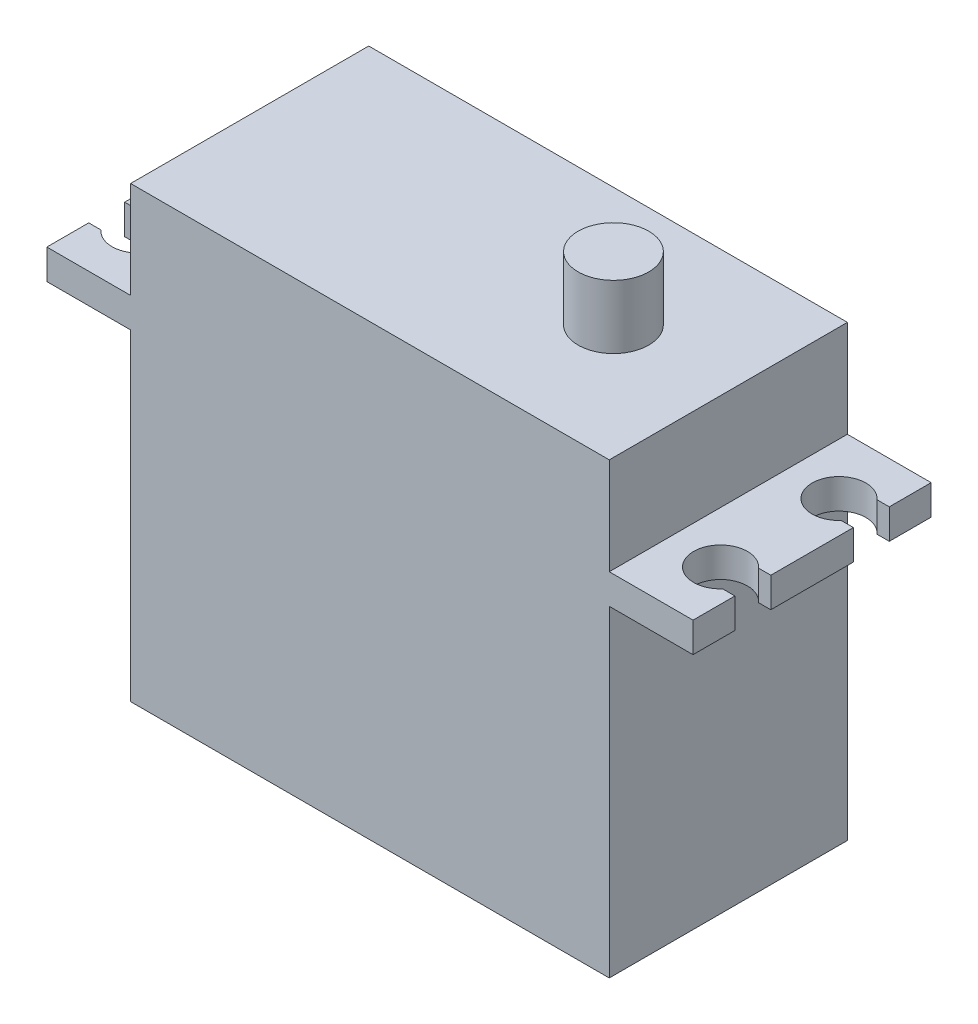
from build123d import *

# Parameters (mm, degrees)
SKETCH1_W           = 40
SKETCH1_H           = 19.9
BOSS_EXTRUDE1_DEPTH = 26.9
BOSS_EXTRUDE2_DEPTH = 2.5
SKETCH5_W           = 40
SKETCH5_H           = 19.9
BOSS_EXTRUDE3_DEPTH = 8.1


with BuildPart() as part:
    # Sketch1 → Boss-Extrude1 (new body)
    with BuildSketch(Plane(origin=(0, 0, 0), x_dir=(1, 0, 0), z_dir=(0, 1, 0))):
        Rectangle(SKETCH1_W, SKETCH1_H)
    extrude(amount=BOSS_EXTRUDE1_DEPTH)

    # Sketch4 → Boss-Extrude2 (add)
    with BuildSketch(Plane(origin=(0, 26.9, 0), x_dir=(1, 0, 0), z_dir=(0, 1, 0))):
        with BuildLine():
            Line((-27, -9.95), (27, -9.95))
            Line((27, -9.95), (27, -6.45))
            Line((27, -6.45), (25.977050983, -6.45))
            ThreePointArc((25.977050983, -6.45), (22.05, -4.95), (25.977050983, -3.45))
            Line((25.977050983, -3.45), (27, -3.45))
            Line((27, -3.45), (27, 3.45))
            Line((27, 3.45), (25.977050983, 3.45))
            ThreePointArc((25.977050983, 3.45), (22.05, 4.95), (25.977050983, 6.45))
            Line((25.977050983, 6.45), (27, 6.45))
            Line((27, 6.45), (27, 9.95))
            Line((27, 9.95), (-27, 9.95))
            Line((-27, 9.95), (-27, 6.45))
            Line((-27, 6.45), (-25.977050983, 6.45))
            ThreePointArc((-25.977050983, 6.45), (-22.05, 4.95), (-25.977050983, 3.45))
            Line((-25.977050983, 3.45), (-27, 3.45))
            Line((-27, 3.45), (-27, -3.45))
            Line((-27, -3.45), (-25.977050983, -3.45))
            ThreePointArc((-25.977050983, -3.45), (-22.05, -4.95), (-25.977050983, -6.45))
            Line((-25.977050983, -6.45), (-27, -6.45))
            Line((-27, -6.45), (-27, -9.95))
        make_face()
    extrude(amount=BOSS_EXTRUDE2_DEPTH)

    # Sketch5 → Boss-Extrude3 (add)
    with BuildSketch(Plane(origin=(0, 29.4, 0), x_dir=(1, 0, 0), z_dir=(0, 1, 0))):
        Rectangle(SKETCH5_W, SKETCH5_H)
    extrude(amount=BOSS_EXTRUDE3_DEPTH)

    # Sketch8 → Cut-Revolve1 (revolve, cut)
    with BuildSketch(Plane.XY):
        Polygon((10.4, 42.8), (10.4, 3), (16.4, 3), (16.4, 25), (13.35, 25), (13.35, 42.8), align=None)
    revolve(axis=Axis((10.4, 42.8, 0), (0, -1, 0)), mode=Mode.SUBTRACT)


with BuildPart() as body_2:
    # Sketch8_2 → Revolve1 (revolve)
    with BuildSketch(Plane.XY):
        Polygon((10.4, 42.8), (10.4, 3), (16.4, 3), (16.4, 25), (13.35, 25), (13.35, 42.8), align=None)
    revolve(axis=Axis((10.4, 42.8, 0), (0, -1, 0)))


solid = Compound([part.part, body_2.part])
